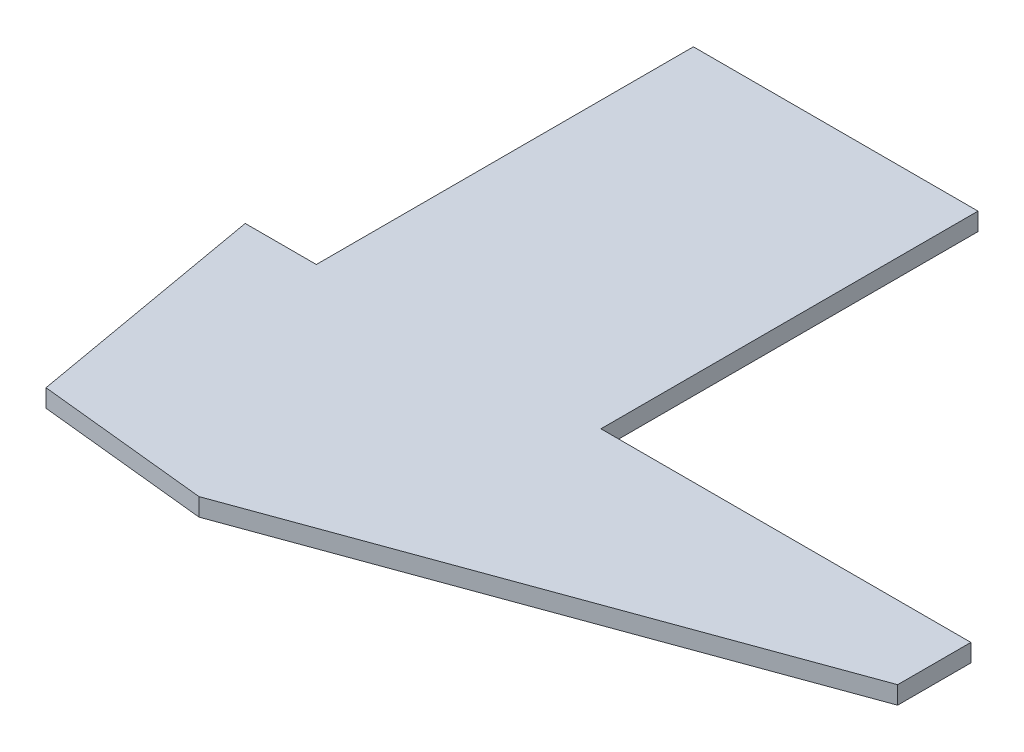
from build123d import *

# Parameters (mm, degrees)
BOSS_EXTRUDE1_DEPTH = 3.175


with BuildPart() as part:
    # Sketch2 → Boss-Extrude1 (new body)
    with BuildSketch(Plane(origin=(0, 0, 0), x_dir=(1, 0, 0), z_dir=(0, 1, 0))):
        Polygon((50.8, 0), (116.84, 0), (116.84, -13.073561779), (25.4, -46.355), (-5.08, -43.18), (-12.7, 0), (0, 0), (0, 67.31), (50.8, 67.31), align=None)
    extrude(amount=BOSS_EXTRUDE1_DEPTH)


solid = part.part
